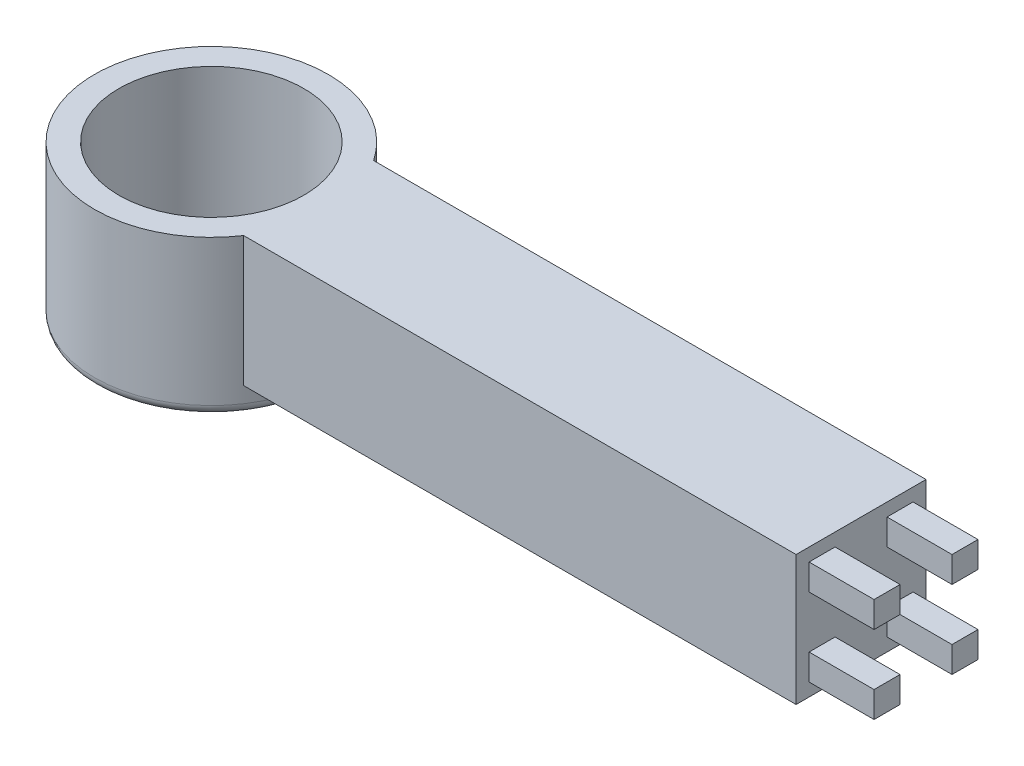
from build123d import *

# Parameters (mm, degrees)
SKETCH2_W               = 635
SKETCH2_H               = 127
BOSS_EXTRUDE1_DEPTH     = 127
SKETCH3_R               = 114.3
SKETCH3_R_2             = 90.424
BOSS_EXTRUDE2_DEPTH     = 152.4
SKETCH4_R               = 90.424
CUT_EXTRUDE2_DEPTH      = 1
CUT_EXTRUDE2_DEPTH_BACK = 153.4
SKETCH5_W               = 25.4
SKETCH5_H               = 25.4
BOSS_EXTRUDE3_DEPTH     = 63.5
FILLET1_R               = 10


with BuildPart() as part:
    # Sketch2 → Boss-Extrude1 (new body)
    with BuildSketch(Plane.XY):
        with Locations((317.5, 63.5)):
            Rectangle(SKETCH2_W, SKETCH2_H)
    extrude(amount=BOSS_EXTRUDE1_DEPTH)

    # Sketch3 → Boss-Extrude2 (add)
    with BuildSketch(Plane(origin=(0, 127, 0), x_dir=(1, 0, 0), z_dir=(0, 1, 0))):
        with Locations((0, -63.5)):
            Circle(SKETCH3_R)
        with Locations((0, -63.5)):
            Circle(SKETCH3_R_2, mode=Mode.SUBTRACT)
    extrude(amount=-BOSS_EXTRUDE2_DEPTH)

    # Sketch4 → Cut-Extrude2 (cut, two sides)
    with BuildSketch(Plane(origin=(0, 127, 0), x_dir=(1, 0, 0), z_dir=(0, 1, 0))) as cut_extrude2_sk:
        with Locations((0, -63.5)):
            Circle(SKETCH4_R)
    extrude(amount=CUT_EXTRUDE2_DEPTH, mode=Mode.SUBTRACT)
    extrude(cut_extrude2_sk.sketch, amount=-CUT_EXTRUDE2_DEPTH_BACK, mode=Mode.SUBTRACT)

    # Sketch5 → Boss-Extrude3 (add)
    with BuildSketch(Plane(origin=(635, 0, 0), x_dir=(0, 0, -1), z_dir=(1, 0, 0))):
        with Locations((-101.6, 101.6)):
            Rectangle(SKETCH5_W, SKETCH5_H)
        with Locations((-25.4, 25.4)):
            Rectangle(SKETCH5_W, SKETCH5_H)
        with Locations((-101.6, 25.4)):
            Rectangle(SKETCH5_W, SKETCH5_H)
        with Locations((-25.4, 101.6)):
            Rectangle(SKETCH5_W, SKETCH5_H)
    extrude(amount=BOSS_EXTRUDE3_DEPTH)

    # Fillet1
    fillet1_edges = [part.edges().sort_by_distance(p)[0] for p in [
        (-114.3, -25.4, 63.5),
        (-90.424, -25.4, 63.5),
    ]]
    fillet(fillet1_edges, radius=FILLET1_R)


solid = part.part
